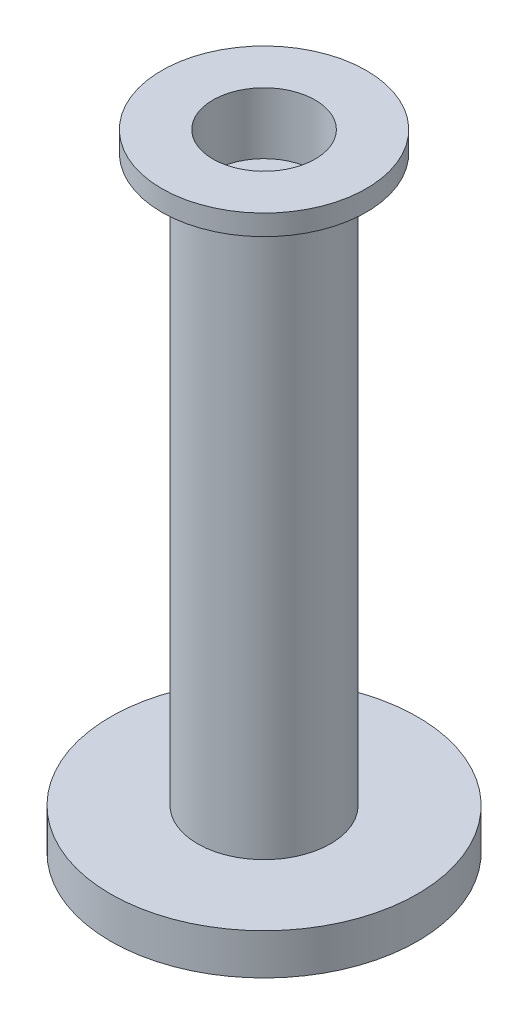
from build123d import *

# Parameters (mm, degrees)
SKETCH1_R           = 3.75
BOSS_EXTRUDE1_DEPTH = 1
SKETCH2_R           = 1.625
BOSS_EXTRUDE2_DEPTH = 13.8
SKETCH3_R           = 2.5
BOSS_EXTRUDE3_DEPTH = 0.5
SKETCH4_R           = 1.25
CUT_EXTRUDE2_DEPTH  = 1.5


with BuildPart() as part:
    # Sketch1 → Boss-Extrude1 (new body)
    with BuildSketch(Plane(origin=(0, 0, 0), x_dir=(1, 0, 0), z_dir=(0, 1, 0))):
        Circle(SKETCH1_R)
    extrude(amount=BOSS_EXTRUDE1_DEPTH)

    # Sketch2 → Boss-Extrude2 (add)
    with BuildSketch(Plane(origin=(0, 1, 0), x_dir=(1, 0, 0), z_dir=(0, 1, 0))):
        Circle(SKETCH2_R)
    extrude(amount=BOSS_EXTRUDE2_DEPTH)

    # Sketch3 → Boss-Extrude3 (add)
    with BuildSketch(Plane(origin=(0, 14.8, 0), x_dir=(1, 0, 0), z_dir=(0, 1, 0))):
        Circle(SKETCH3_R)
    extrude(amount=BOSS_EXTRUDE3_DEPTH)

    # Sketch4 → Cut-Extrude2 (cut)
    with BuildSketch(Plane(origin=(0, 15.3, 0), x_dir=(1, 0, 0), z_dir=(0, 1, 0))):
        Circle(SKETCH4_R)
    extrude(amount=-CUT_EXTRUDE2_DEPTH, mode=Mode.SUBTRACT)


solid = part.part
